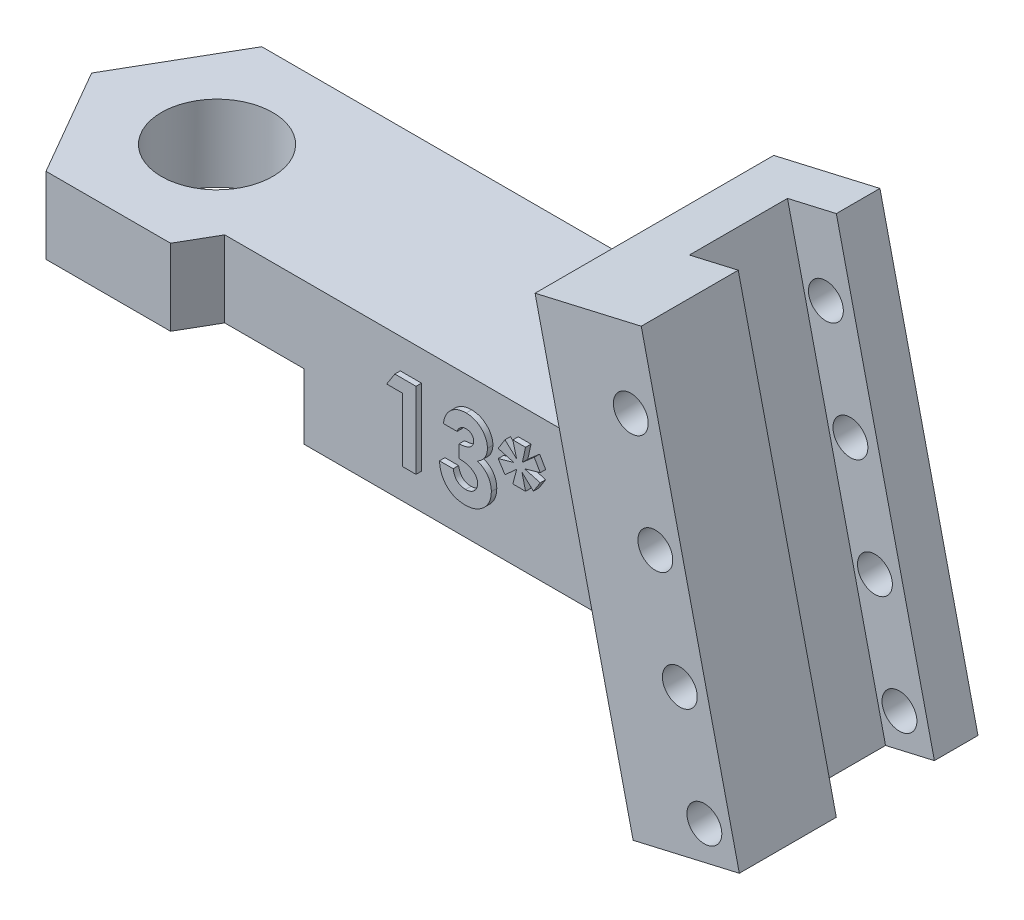
from build123d import *

# Parameters (mm, degrees)
SKETCH1_W                = 25
SKETCH1_H                = 6.75
BOSS_EXTRUDE1_DEPTH      = 6.5
BOSS_EXTRUDE4_DEPTH      = 6.5
BOSS_EXTRUDE3_DEPTH      = 6
BOSS_EXTRUDE3_DEPTH_BACK = 4.95
SKETCH4_W                = 2.3
SKETCH4_H                = 4.5
CUT_EXTRUDE1_DEPTH       = 23
SKETCH6_R                = 2.55
CUT_EXTRUDE2_DEPTH       = 10
BOSS_EXTRUDE5_DEPTH      = 1.575
CUT_EXTRUDE3_DEPTH       = 3
SKETCH9_R                = 0.8
CUT_EXTRUDE4_DEPTH       = 10.95
BOSS_EXTRUDE6_DEPTH      = 0.25


with BuildPart() as part:
    # Sketch1 → Boss-Extrude1 (new body)
    with BuildSketch(Plane(origin=(0, 0, 0), x_dir=(1, 0, 0), z_dir=(0, 1, 0))):
        with Locations((12.5, -3.375)):
            Rectangle(SKETCH1_W, SKETCH1_H)
    extrude(amount=BOSS_EXTRUDE1_DEPTH)

    # Sketch5 → Boss-Extrude4 (add)
    with BuildSketch(Plane(origin=(0, 6.5, 0), x_dir=(1, 0, 0), z_dir=(0, 1, 0))):
        Polygon((-5.715767665, -3.375), (-2.857883832, -8.325), (2.857883832, -8.325), (5.715767665, -3.375), (2.857883832, 1.575), (-2.857883832, 1.575), align=None)
    extrude(amount=-BOSS_EXTRUDE4_DEPTH)

    # Sketch3 → Boss-Extrude3 (add, two sides)
    with BuildSketch(Plane.XY.offset(3.375)) as boss_extrude3_sk:
        Polygon((20.629128589, 13.92502366), (25.500978913, 15.049778932), (30, -4.437622364), (25.128149676, -5.562377636), align=None)
    extrude(amount=BOSS_EXTRUDE3_DEPTH)
    extrude(boss_extrude3_sk.sketch, amount=-BOSS_EXTRUDE3_DEPTH_BACK)

    # Sketch4 → Cut-Extrude1 (cut)
    with BuildSketch(Plane(origin=(-2.008268979, 8.698768631, 0), x_dir=(0.974370065, 0.224951054, 0), z_dir=(-0.224951054, 0.974370065, 0))):
        with Locations((27.082854114, -2.675)):
            Rectangle(SKETCH4_W, SKETCH4_H)
    extrude(amount=-CUT_EXTRUDE1_DEPTH, mode=Mode.SUBTRACT)

    # Sketch6 → Cut-Extrude2 (cut)
    with BuildSketch(Plane(origin=(0, 6.5, 0), x_dir=(1, 0, 0), z_dir=(0, 1, 0))):
        with Locations((0, -3.335615973)):
            Circle(SKETCH6_R)
    extrude(amount=-CUT_EXTRUDE2_DEPTH, mode=Mode.SUBTRACT)

    # Sketch7 → Boss-Extrude5 (add)
    with BuildSketch(Plane(origin=(0, 0, -1.575), x_dir=(-1, 0, 0), z_dir=(0, 0, -1))):
        Polygon((-2.857883832, 0), (-23.843973613, 0), (-25.128149676, -5.562377636), (-30, -4.437622364), (-25.500978913, 15.049778932), (-20.629128589, 13.92502366), (-22.343330371, 6.5), (-2.857883832, 6.5), align=None)
    extrude(amount=-BOSS_EXTRUDE5_DEPTH)

    # Sketch8 → Cut-Extrude3 (cut)
    with BuildSketch(Plane(origin=(0, 0, 0), x_dir=(-1, 0, 0), z_dir=(0, -1, 0))):
        Polygon((-4.67653718, -11.475), (4.67653718, -11.475), (9.353074361, -3.375), (4.67653718, 4.725), (-4.67653718, 4.725), (-9.353074361, -3.375), align=None)
    extrude(amount=-CUT_EXTRUDE3_DEPTH, mode=Mode.SUBTRACT)

    # Sketch9 → Cut-Extrude4 (cut)
    with BuildSketch(Plane(origin=(0, 0, -1.575), x_dir=(-1, 0, 0), z_dir=(0, 0, -1))):
        with Locations((-28.395892334, -3.268503638)):
            Circle(SKETCH9_R)
        with Locations((-27.271137063, 1.603346686)):
            Circle(SKETCH9_R)
        with Locations((-26.146381791, 6.47519701)):
            Circle(SKETCH9_R)
        with Locations((-25.021626519, 11.347047334)):
            Circle(SKETCH9_R)
    extrude(amount=-CUT_EXTRUDE4_DEPTH, mode=Mode.SUBTRACT)

    # Sketch10 → Boss-Extrude6 (add)
    with BuildSketch(Plane.XY.offset(6.75)):
        Polygon((11.821517388, 5.121255448), (12.792571074, 5.121255448), (12.792571074, 1.621255448), (12.164365946, 1.621255448), (12.164365946, 4.537922115), (11.446417228, 4.537922115), align=None)
        with BuildLine():
            Line((14.677186459, 4.268691346), (14.048981331, 4.268691346))
            add(Edge.make_bspline(
                [(14.048981331, 4.268691346), (14.053416698, 4.300093079), (14.062111941, 4.361654097), (14.082918496, 4.450779115), (14.10780538, 4.535320295), (14.138875384, 4.615009911), (14.175315444, 4.689989916), (14.216755005, 4.760517607), (14.263642045, 4.826290264), (14.299581458, 4.865911974), (14.317510978, 4.885678525)],
                knots=[0, 0, 0, 0, 9.5097e-05, 0.000186431, 0.000274271, 0.000359292, 0.000442701, 0.000524107, 0.00060447, 0.000684475, 0.000684475, 0.000684475, 0.000684475], degree=3))
            add(Edge.make_bspline(
                [(14.317510978, 4.885678525), (14.343371935, 4.911759057), (14.394341163, 4.963161045), (14.479516721, 5.029001313), (14.568796436, 5.085981588), (14.663970851, 5.131155962), (14.763558982, 5.167719384), (14.868352786, 5.192279118), (14.97792404, 5.208574718), (15.052692636, 5.210179891), (15.090848318, 5.210999038)],
                knots=[0, 0, 0, 0, 0.000110078, 0.000216953, 0.000322189, 0.00042724, 0.000532366, 0.00063984, 0.000749603, 0.000863991, 0.000863991, 0.000863991, 0.000863991], degree=3))
            add(Edge.make_bspline(
                [(15.090848318, 5.210999038), (15.124770682, 5.210198198), (15.191455214, 5.208623906), (15.289464698, 5.195986351), (15.382908539, 5.173821487), (15.472774465, 5.144841425), (15.557740842, 5.105409206), (15.639682959, 5.059636794), (15.716311353, 5.003495027), (15.787805317, 4.940060481), (15.853486159, 4.87144981), (15.910366056, 4.798110645), (15.959266723, 4.722002044), (15.999554406, 4.642491689), (16.030530159, 4.559445039), (16.05202825, 4.473341842), (16.066099272, 4.384372093), (16.067501114, 4.323900552), (16.0682121, 4.293230609)],
                knots=[0, 0, 0, 0, 0.00010175, 0.000200019, 0.000295768, 0.000389553, 0.000482742, 0.000576315, 0.000670698, 0.000767061, 0.000862777, 0.0009552, 0.001045055, 0.001133791, 0.001222088, 0.001310343, 0.001399683, 0.001491626, 0.001491626, 0.001491626, 0.001491626], degree=3))
            add(Edge.make_bspline(
                [(16.0682121, 4.293230609), (16.066753115, 4.255248437), (16.063880821, 4.180473219), (16.040311576, 4.071034132), (16.003419298, 3.966390834), (15.950124814, 3.868007443), (15.883493135, 3.776151703), (15.801738296, 3.693894628), (15.707188888, 3.619946537), (15.636209388, 3.580206824), (15.599862741, 3.559857211)],
                knots=[0, 0, 0, 0, 0.000113843, 0.000224122, 0.000334341, 0.000445696, 0.000558585, 0.000673608, 0.000792534, 0.000917346, 0.000917346, 0.000917346, 0.000917346], degree=3))
            add(Edge.make_bspline(
                [(15.599862741, 3.559857211), (15.624810522, 3.551666329), (15.673831793, 3.535571614), (15.743509636, 3.503873254), (15.809765302, 3.469232201), (15.871457894, 3.428988428), (15.929201018, 3.384769217), (15.982642665, 3.336196564), (16.032102137, 3.283376382), (16.076772029, 3.226018179), (16.116418303, 3.165039287), (16.151990794, 3.101848284), (16.181268936, 3.035486866), (16.206071168, 2.966712925), (16.224954175, 2.894908358), (16.2382495, 2.820351401), (16.245934524, 2.743212123), (16.247106621, 2.690950309), (16.247699279, 2.664524679)],
                knots=[0, 0, 0, 0, 7.8716e-05, 0.000154674, 0.000229323, 0.000302834, 0.000375335, 0.000447305, 0.000519234, 0.000592164, 0.000665087, 0.000737272, 0.000809457, 0.000882418, 0.000956395, 0.001031899, 0.001109407, 0.001188683, 0.001188683, 0.001188683, 0.001188683], degree=3))
            add(Edge.make_bspline(
                [(16.247699279, 2.664524679), (16.246497881, 2.625689732), (16.244128968, 2.549115124), (16.229068528, 2.436328565), (16.201028703, 2.3287966), (16.16414076, 2.225281914), (16.114936247, 2.127120843), (16.057030808, 2.032060724), (15.985853388, 1.943398216), (15.906751908, 1.858789313), (15.818905103, 1.781866686), (15.723664875, 1.71517823), (15.623125475, 1.65794767), (15.516650819, 1.61148627), (15.404277898, 1.575705679), (15.286257182, 1.549841818), (15.16209278, 1.53401788), (15.077340862, 1.53235904), (15.034057452, 1.531511859)],
                knots=[0, 0, 0, 0, 0.000116521, 0.000229756, 0.000340458, 0.000449358, 0.000558789, 0.000669302, 0.000782635, 0.000899192, 0.001016461, 0.0011322, 0.001247427, 0.001362968, 0.00148004, 0.001600652, 0.001725009, 0.00185481, 0.00185481, 0.00185481, 0.00185481], degree=3))
            add(Edge.make_bspline(
                [(15.034057452, 1.531511859), (14.993112045, 1.532405068), (14.91304872, 1.534151621), (14.79593935, 1.549268922), (14.684637979, 1.573654356), (14.578860564, 1.608027647), (14.47901635, 1.652603931), (14.384199909, 1.705684283), (14.296303285, 1.770330255), (14.214347134, 1.843623605), (14.140149491, 1.925854582), (14.073834272, 2.015118347), (14.016863739, 2.111754333), (13.969004254, 2.21534967), (13.93062997, 2.326086097), (13.900360448, 2.443738424), (13.879216691, 2.568536509), (13.872777316, 2.654400246), (13.869494151, 2.698178525)],
                knots=[0, 0, 0, 0, 0.000122794, 0.000240108, 0.000353571, 0.000464208, 0.000573126, 0.000681135, 0.00078954, 0.000899761, 0.001010452, 0.001121231, 0.001232817, 0.001346375, 0.00146301, 0.001583917, 0.001710477, 0.001842127, 0.001842127, 0.001842127, 0.001842127], degree=3))
            Line((13.869494151, 2.698178525), (14.497699279, 2.698178525))
            add(Edge.make_bspline(
                [(14.497699279, 2.698178525), (14.50168015, 2.676166232), (14.509433939, 2.633291517), (14.524557229, 2.571218462), (14.544264985, 2.513921197), (14.567052056, 2.460890468), (14.591665522, 2.411429999), (14.621404475, 2.367366487), (14.654089801, 2.327503427), (14.701254965, 2.280113782), (14.768680815, 2.2314229), (14.85972805, 2.189108207), (14.961009477, 2.164306599), (15.031815296, 2.161280879), (15.06841242, 2.159716987)],
                knots=[0, 0, 0, 0, 6.7103e-05, 0.0001307, 0.000191452, 0.000248622, 0.000303811, 0.000356897, 0.000407708, 0.000458276, 0.000557145, 0.000655327, 0.000757866, 0.000867564, 0.000867564, 0.000867564, 0.000867564], degree=3))
            add(Edge.make_bspline(
                [(15.06841242, 2.159716987), (15.087832148, 2.160050003), (15.12587105, 2.160702307), (15.181744534, 2.167932223), (15.234971893, 2.179839901), (15.285652269, 2.196021993), (15.334108294, 2.216307258), (15.379414167, 2.242463893), (15.422493337, 2.272874715), (15.462877493, 2.307064552), (15.500193284, 2.344319236), (15.531242218, 2.385572468), (15.559618696, 2.427493126), (15.580606144, 2.472823806), (15.59899567, 2.519125233), (15.610250999, 2.568078005), (15.618749581, 2.618655222), (15.619243485, 2.65326805), (15.619494151, 2.670834775)],
                knots=[0, 0, 0, 0, 5.8231e-05, 0.000114062, 0.000168664, 0.000221658, 0.000273488, 0.000325928, 0.000378254, 0.000431488, 0.000484538, 0.000536007, 0.00058618, 0.000636039, 0.000685521, 0.000735345, 0.000786412, 0.000839038, 0.000839038, 0.000839038, 0.000839038], degree=3))
            add(Edge.make_bspline(
                [(15.619494151, 2.670834775), (15.618828679, 2.690046982), (15.617503877, 2.728294085), (15.606680106, 2.784107688), (15.589587083, 2.837795876), (15.565842786, 2.889120893), (15.534134924, 2.937893563), (15.49672, 2.985092416), (15.450650338, 3.028260834), (15.400105749, 3.070931508), (15.341493882, 3.108127465), (15.277669217, 3.142453869), (15.206954343, 3.169767089), (15.131075474, 3.194162853), (15.048597289, 3.211981141), (14.960031948, 3.224918954), (14.865522319, 3.234549151), (14.800375604, 3.235930761), (14.766930048, 3.236640064)],
                knots=[0, 0, 0, 0, 5.7599e-05, 0.000114666, 0.000169877, 0.000226338, 0.000283714, 0.000344047, 0.000406522, 0.000472773, 0.000542199, 0.000614332, 0.000689846, 0.00076923, 0.000853263, 0.000942603, 0.001037692, 0.001138014, 0.001138014, 0.001138014, 0.001138014], degree=3))
            Line((14.766930048, 3.236640064), (14.766930048, 3.819973397))
            add(Edge.make_bspline(
                [(14.766930048, 3.819973397), (14.808571754, 3.823519738), (14.886475139, 3.830154239), (14.994609213, 3.845669252), (15.085644165, 3.86640762), (15.161768021, 3.891427339), (15.224976393, 3.923559177), (15.280194878, 3.959031307), (15.327751649, 4.000227002), (15.3679435, 4.045917811), (15.400095731, 4.094985456), (15.422851206, 4.14666728), (15.437877734, 4.199364183), (15.439301496, 4.235407276), (15.440006972, 4.253266666)],
                knots=[0, 0, 0, 0, 0.000125368, 0.000234538, 0.000327396, 0.000405221, 0.000474202, 0.000539542, 0.000601673, 0.000662287, 0.000721601, 0.000776843, 0.000831265, 0.000884716, 0.000884716, 0.000884716, 0.000884716], degree=3))
            add(Edge.make_bspline(
                [(15.440006972, 4.253266666), (15.438789824, 4.276053309), (15.43641421, 4.32052801), (15.417963903, 4.384180677), (15.38593626, 4.440921754), (15.342992815, 4.490631842), (15.290664733, 4.532153433), (15.229327049, 4.5622974), (15.160310793, 4.580008327), (15.111754138, 4.581844353), (15.086641587, 4.58279391)],
                knots=[0, 0, 0, 0, 6.8301e-05, 0.000133309, 0.000196709, 0.000262338, 0.000329243, 0.000395716, 0.000465948, 0.000541177, 0.000541177, 0.000541177, 0.000541177], degree=3))
            add(Edge.make_bspline(
                [(15.086641587, 4.58279391), (15.063879883, 4.581673533), (15.01871369, 4.579450361), (14.952667197, 4.562857197), (14.889945034, 4.53492467), (14.831845998, 4.496407362), (14.779208762, 4.450149708), (14.736008777, 4.395367119), (14.700077079, 4.335341713), (14.684846578, 4.290995231), (14.677186459, 4.268691346)],
                knots=[0, 0, 0, 0, 6.824e-05, 0.000135409, 0.000202895, 0.00027329, 0.000343801, 0.000412127, 0.000481874, 0.000552447, 0.000552447, 0.000552447, 0.000552447], degree=3))
        make_face()
        Polygon((17.234878766, 5.210999038), (17.8182121, 5.210999038), (17.672378766, 4.537922115), (18.215748157, 5.013983814), (18.491289023, 4.537922115), (17.773340305, 4.335999038), (18.491289023, 4.134075961), (18.180692068, 3.647497435), (17.6541496, 4.134075961), (17.8182121, 3.460999038), (17.234878766, 3.460999038), (17.412262581, 4.134075961), (16.873801042, 3.647497435), (16.561801843, 4.134075961), (17.279750561, 4.335999038), (16.561801843, 4.537922115), (16.873801042, 5.036419711), (17.412262581, 4.537922115), align=None)
    extrude(amount=BOSS_EXTRUDE6_DEPTH)


solid = part.part
